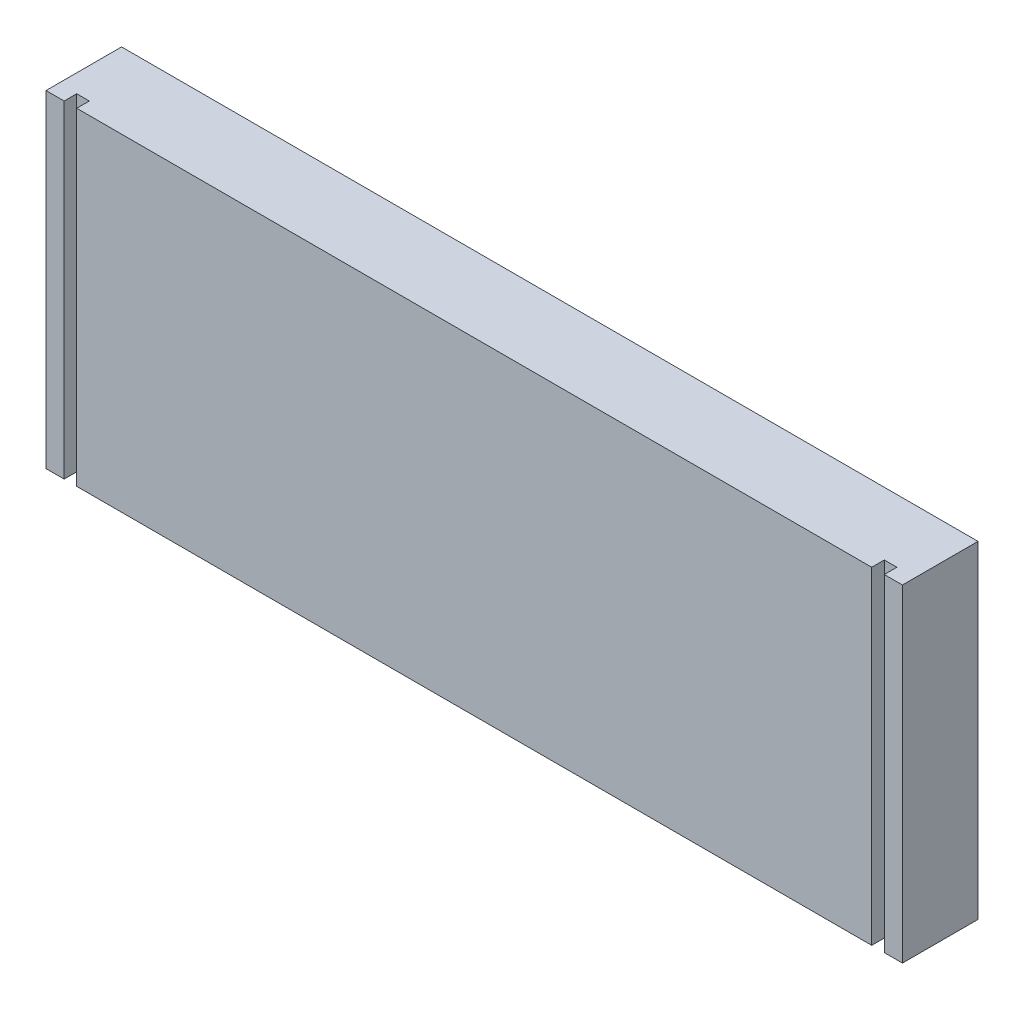
from build123d import *

# Parameters (mm, degrees)
SKETCH1_W           = 215.9
SKETCH1_H           = 82.55
BOSS_EXTRUDE2_DEPTH = 19.05
SKETCH3_R           = 4.7625
CUT_EXTRUDE1_DEPTH  = 19.05
SKETCH5_W           = 3.175
SKETCH5_H           = 3.175
CUT_EXTRUDE2_DEPTH  = 83.55


with BuildPart() as part:
    # Sketch1 → Boss-Extrude2 (new body)
    with BuildSketch(Plane.XY):
        Rectangle(SKETCH1_W, SKETCH1_H)
    extrude(amount=BOSS_EXTRUDE2_DEPTH)

    # Sketch3 → Cut-Extrude1 (cut)
    with BuildSketch(Plane.XZ.offset(41.275)):
        with Locations((-82.55, 9.525)):
            Circle(SKETCH3_R)
    cut_extrude1 = extrude(amount=-CUT_EXTRUDE1_DEPTH, mode=Mode.SUBTRACT)

    # Sketch5 → Cut-Extrude2 (cut, through all)
    with BuildSketch(Plane.XZ.offset(41.275)):
        with Locations((-101.7905, 17.4625)):
            Rectangle(SKETCH5_W, SKETCH5_H)
    cut_extrude2 = extrude(amount=-CUT_EXTRUDE2_DEPTH, mode=Mode.SUBTRACT)

    # Mirror1: Cut-Extrude1, Cut-Extrude2 across plane
    add(cut_extrude1.mirror(Plane(origin=(0, 0, 0), x_dir=(0, 0, 1), z_dir=(1, 0, 0))), mode=Mode.SUBTRACT)
    add(cut_extrude2.mirror(Plane(origin=(0, 0, 0), x_dir=(0, 0, 1), z_dir=(1, 0, 0))), mode=Mode.SUBTRACT)


solid = part.part
